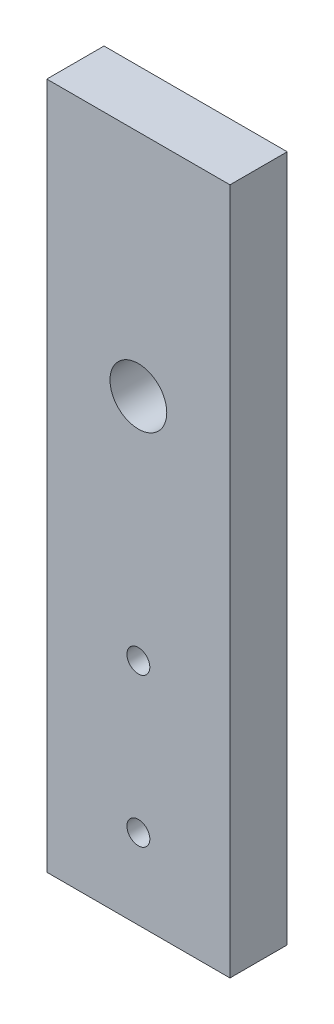
from build123d import *

# Parameters (mm, degrees)
SKETCH1_W           = 80
SKETCH1_H           = 300
SKETCH1_R           = 12.4
SKETCH1_R_2         = 5
BOSS_EXTRUDE2_DEPTH = 25


with BuildPart() as part:
    # Sketch1 → Boss-Extrude2 (new body)
    with BuildSketch(Plane.XY):
        with Locations((-40, 150)):
            Rectangle(SKETCH1_W, SKETCH1_H)
        with Locations((-40, 200)):
            Circle(SKETCH1_R, mode=Mode.SUBTRACT)
        with Locations((-40, 35)):
            Circle(SKETCH1_R_2, mode=Mode.SUBTRACT)
        with Locations((-40, 100)):
            Circle(SKETCH1_R_2, mode=Mode.SUBTRACT)
    extrude(amount=-BOSS_EXTRUDE2_DEPTH)


solid = part.part
